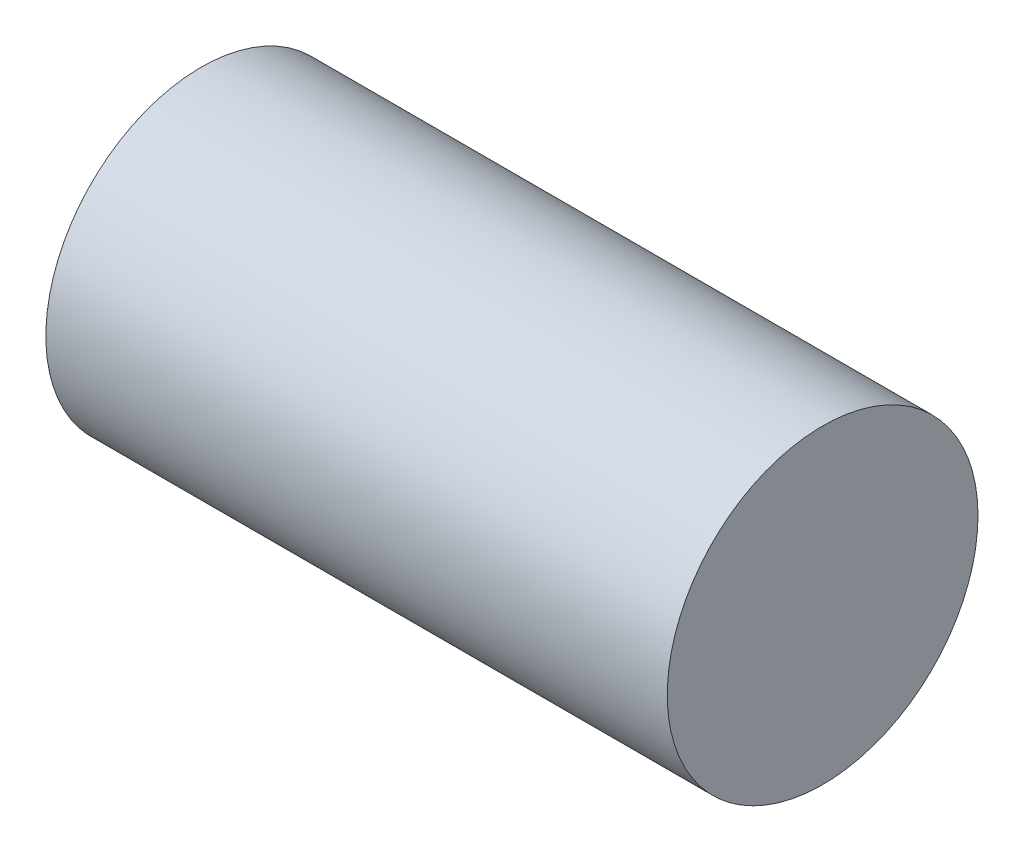
from build123d import *

# Parameters (mm, degrees)
SKETCH1_R           = 2.38125
BOSS_EXTRUDE1_DEPTH = 9.525


with BuildPart() as part:
    # Sketch1 → Boss-Extrude1 (new body)
    with BuildSketch(Plane(origin=(0, 0, 0), x_dir=(0, 0, -1), z_dir=(1, 0, 0))):
        Circle(SKETCH1_R)
    extrude(amount=BOSS_EXTRUDE1_DEPTH)


solid = part.part
